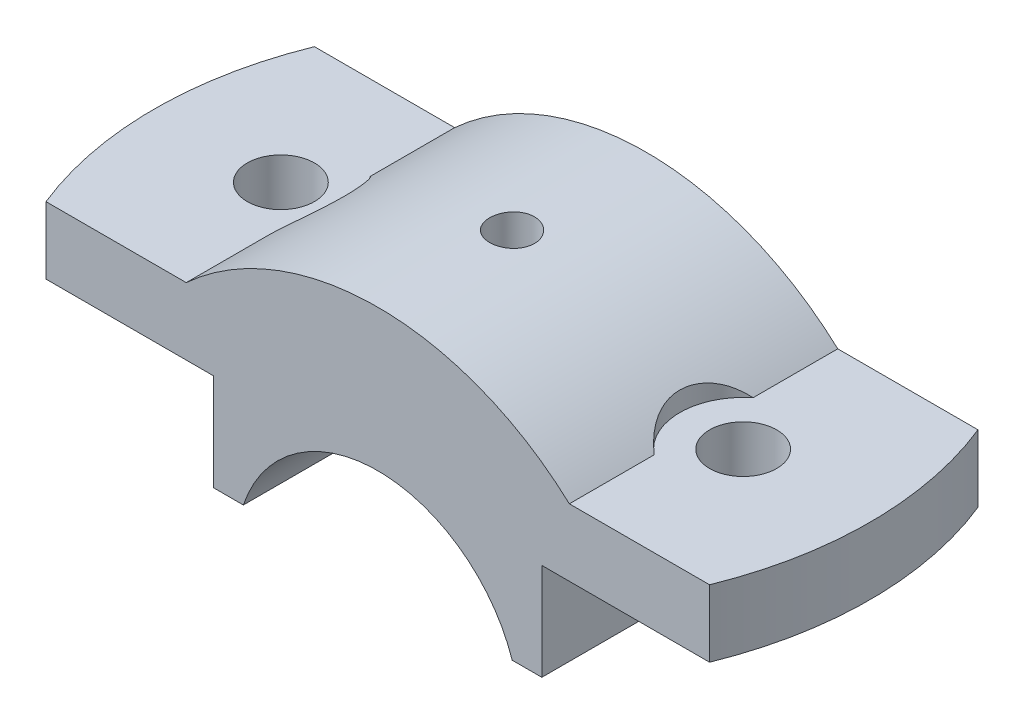
from build123d import *

# Parameters (mm, degrees)
BOSS_EXTRUDE1_DEPTH                 = 18
F_6_0MM_DOWEL_HOLE1_D               = 9
CUT_EXTRUDE2_DEPTH                  = 10
F_6_0MM_DOWEL_HOLE2_D               = 6
F_6_0MM_DOWEL_HOLE2_DEPTH           = 13
F_6_0MM_DOWEL_HOLE2_TIP             = 3
F_6_0MM_DOWEL_HOLE2_ON_FACE_2_D     = 6
F_6_0MM_DOWEL_HOLE2_ON_FACE_2_DEPTH = 13
F_6_0MM_DOWEL_HOLE2_ON_FACE_2_TIP   = 3
F_5_0MM_DOWEL_HOLE2_D               = 5
CUT_EXTRUDE3_START                  = -23.0000001
CUT_EXTRUDE3_DEPTH                  = 34.000000209


with BuildPart() as part:
    # Sketch1 → Boss-Extrude1 (new body, symmetric)
    with BuildSketch(Plane.XY):
        with BuildLine():
            Line((18.027756377, 6), (22, 6))
            Line((22, 6), (22, 19))
            Line((22, 19), (50, 19))
            Line((50, 19), (50, 28))
            Line((50, 28), (25.690465157, 28))
            ThreePointArc((25.690465157, 28), (0, 38), (-25.690465157, 28))
            Line((-25.690465157, 28), (-50, 28))
            Line((-50, 28), (-50, 19))
            Line((-50, 19), (-22, 19))
            Line((-22, 19), (-22, 6))
            Line((-22, 6), (-18.027756377, 6))
            ThreePointArc((-18.027756377, 6), (0, 19), (18.027756377, 6))
        make_face()
    extrude(amount=BOSS_EXTRUDE1_DEPTH, both=True)

    # Ø6.0mm Dowel Hole1 (through all)
    with Locations(Plane(origin=(0, 28, 0), x_dir=(1, 0, 0), z_dir=(0, 1, 0))):
        with Locations((-31, 0)):
            f_6_0mm_dowel_hole1 = Hole(F_6_0MM_DOWEL_HOLE1_D / 2)

    # Mirror1: Ø6.0mm Dowel Hole1 across plane
    add(f_6_0mm_dowel_hole1.mirror(Plane(origin=(0, 0, 0), x_dir=(0, 0, 1), z_dir=(1, 0, 0))), mode=Mode.SUBTRACT)

    # Sketch6 → Cut-Extrude2 (cut)
    with BuildSketch(Plane(origin=(0, 28, 0), x_dir=(1, 0, 0), z_dir=(0, 1, 0))):
        with BuildLine():
            Line((-25.690465157, -6.637683312), (-25.690465157, 6.637683312))
            ThreePointArc((-25.690465157, 6.637683312), (-22.5, 0), (-25.690465157, -6.637683312))
        make_face()
    cut_extrude2 = extrude(amount=CUT_EXTRUDE2_DEPTH, mode=Mode.SUBTRACT)

    # Mirror3: Cut-Extrude2 across plane
    add(cut_extrude2.mirror(Plane(origin=(0, 0, 0), x_dir=(0, 0, 1), z_dir=(1, 0, 0))), mode=Mode.SUBTRACT)

    # Ø6.0mm Dowel Hole2
    with Locations(Plane(origin=(0.004931503, 37.99999968, 0), x_dir=(0.999999992, -0.000129776, 0), z_dir=(0.000129776, 0.999999992, 0))):
        with Locations((0, 0)):
            Hole(F_6_0MM_DOWEL_HOLE2_D / 2, depth=F_6_0MM_DOWEL_HOLE2_DEPTH)
            with Locations((0, 0, -(F_6_0MM_DOWEL_HOLE2_DEPTH + F_6_0MM_DOWEL_HOLE2_TIP / 2))):  # 90° drill point
                Cone(0, F_6_0MM_DOWEL_HOLE2_D / 2, F_6_0MM_DOWEL_HOLE2_TIP, mode=Mode.SUBTRACT)

    # Ø6.0mm Dowel Hole2 on face 2
    with Locations(Plane(origin=(0, 0, 0), x_dir=(0.999999992, -0.000129776, 0), z_dir=(0.000129776, 0.999999992, 0))):
        with Locations((0, 0)):
            Hole(F_6_0MM_DOWEL_HOLE2_ON_FACE_2_D / 2, depth=F_6_0MM_DOWEL_HOLE2_ON_FACE_2_DEPTH)
            with Locations((0, 0, -(F_6_0MM_DOWEL_HOLE2_ON_FACE_2_DEPTH + F_6_0MM_DOWEL_HOLE2_ON_FACE_2_TIP / 2))):  # 90° drill point
                Cone(0, F_6_0MM_DOWEL_HOLE2_ON_FACE_2_D / 2, F_6_0MM_DOWEL_HOLE2_ON_FACE_2_TIP, mode=Mode.SUBTRACT)

    # Ø5.0mm Dowel Hole2 (through all)
    with Locations(Plane(origin=(-1.0606e-05, 19, 0), x_dir=(-1, -5.58e-07, 0), z_dir=(5.58e-07, -1, 0))):
        with Locations((0, 0)):
            Hole(F_5_0MM_DOWEL_HOLE2_D / 2)

    # Sketch12 → Cut-Extrude3 (cut)
    with BuildSketch(Plane(origin=(0, 28, 0), x_dir=(1, 0, 0), z_dir=(0, 1, 0)).offset(CUT_EXTRUDE3_START)):
        with BuildLine():
            Line((35.09453238, -214.75600598), (-44.497190923, -18))
            ThreePointArc((-44.497190923, -18), (-48, 0), (-44.497190923, 18))
            Line((-44.497190923, 18), (35.09453238, 214.75600598))
            Line((35.09453238, 214.75600598), (-389.394658565, 214.75600598))
            Line((-389.394658565, 214.75600598), (-389.394658565, -214.75600598))
            Line((-389.394658565, -214.75600598), (35.09453238, -214.75600598))
        make_face()
    cut_extrude3 = extrude(amount=CUT_EXTRUDE3_DEPTH, mode=Mode.SUBTRACT)

    # Mirror4: Cut-Extrude3 across plane
    add(cut_extrude3.mirror(Plane(origin=(0, 0, 0), x_dir=(0, 0, 1), z_dir=(1, 0, 0))), mode=Mode.SUBTRACT)


solid = part.part
